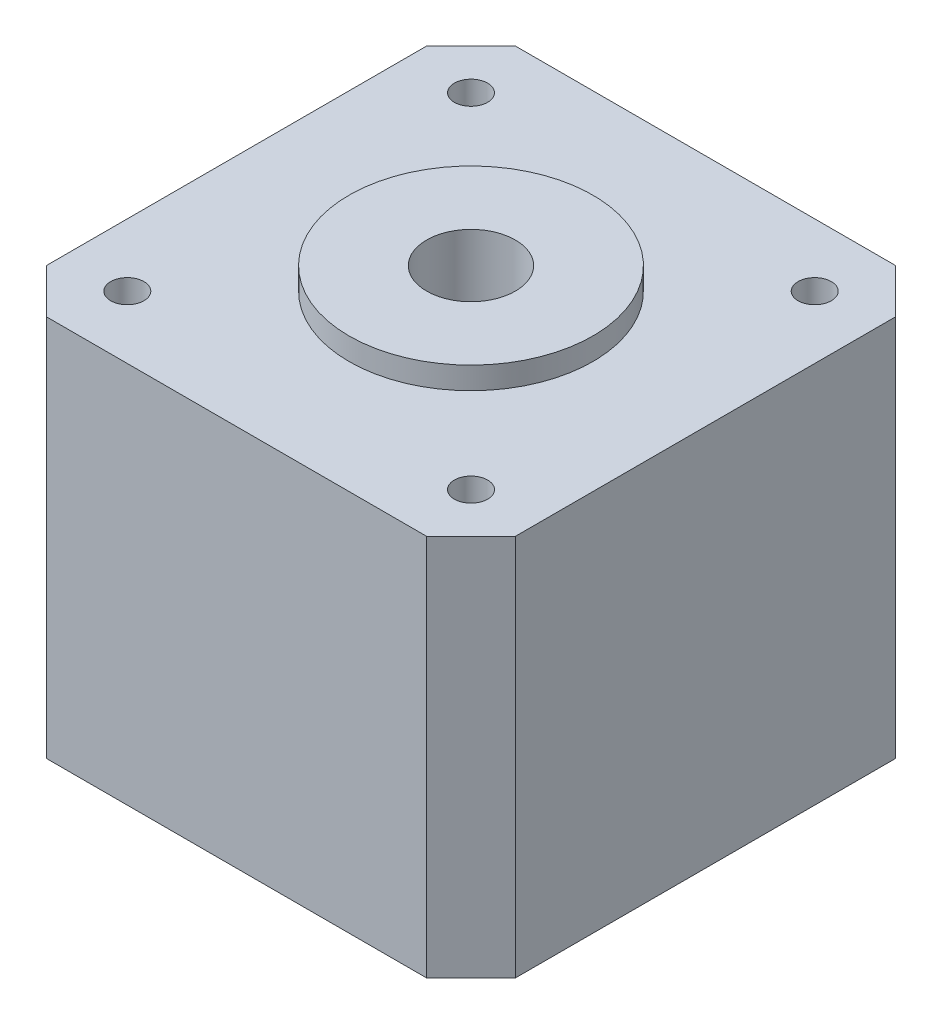
from build123d import *

# Parameters (mm, degrees)
SKETCH_1_W          = 42.3
SKETCH_1_H          = 42.3
EXTRUDE_1_DEPTH     = 34.5
SKETCH_2_R          = 11
EXTRUDE_2_DEPTH     = 2
SKETCH_3_R          = 1.5
CUT_EXTRUDE_1_DEPTH = 5
SKETCH_4_R          = 4
CUT_EXTRUDE_2_DEPTH = 37.5
CHAMFER_1_SIZE      = 4


with BuildPart() as part:
    # 草图1 → 凸台-拉伸1 (new body)
    with BuildSketch(Plane(origin=(0, 0, 0), x_dir=(1, 0, 0), z_dir=(0, 1, 0))):
        Rectangle(SKETCH_1_W, SKETCH_1_H)
    extrude(amount=EXTRUDE_1_DEPTH)

    # 草图2 → 凸台-拉伸2 (add)
    with BuildSketch(Plane(origin=(0, 34.5, 0), x_dir=(1, 0, 0), z_dir=(0, 1, 0))):
        Circle(SKETCH_2_R)
    extrude(amount=EXTRUDE_2_DEPTH)

    # 草图3 → 切除-拉伸1 (cut)
    with BuildSketch(Plane(origin=(0, 34.5, 0), x_dir=(1, 0, 0), z_dir=(0, 1, 0))):
        with Locations((-15.5, 15.5)):
            Circle(SKETCH_3_R)
        with Locations((15.5, 15.5)):
            Circle(SKETCH_3_R)
        with Locations((15.5, -15.5)):
            Circle(SKETCH_3_R)
        with Locations((-15.5, -15.5)):
            Circle(SKETCH_3_R)
    extrude(amount=-CUT_EXTRUDE_1_DEPTH, mode=Mode.SUBTRACT)

    # 草图4 → 切除-拉伸2 (cut, through all)
    with BuildSketch(Plane(origin=(0, 36.5, 0), x_dir=(1, 0, 0), z_dir=(0, 1, 0))):
        Circle(SKETCH_4_R)
    extrude(amount=-CUT_EXTRUDE_2_DEPTH, mode=Mode.SUBTRACT)

    # 倒角1
    chamfer_1_edges = [part.edges().sort_by_distance(p)[0] for p in [
        (21.15, 17.25, 21.15),
        (-21.15, 17.25, 21.15),
        (-21.15, 17.25, -21.15),
        (21.15, 17.25, -21.15),
    ]]
    chamfer(chamfer_1_edges, length=CHAMFER_1_SIZE)


solid = part.part
